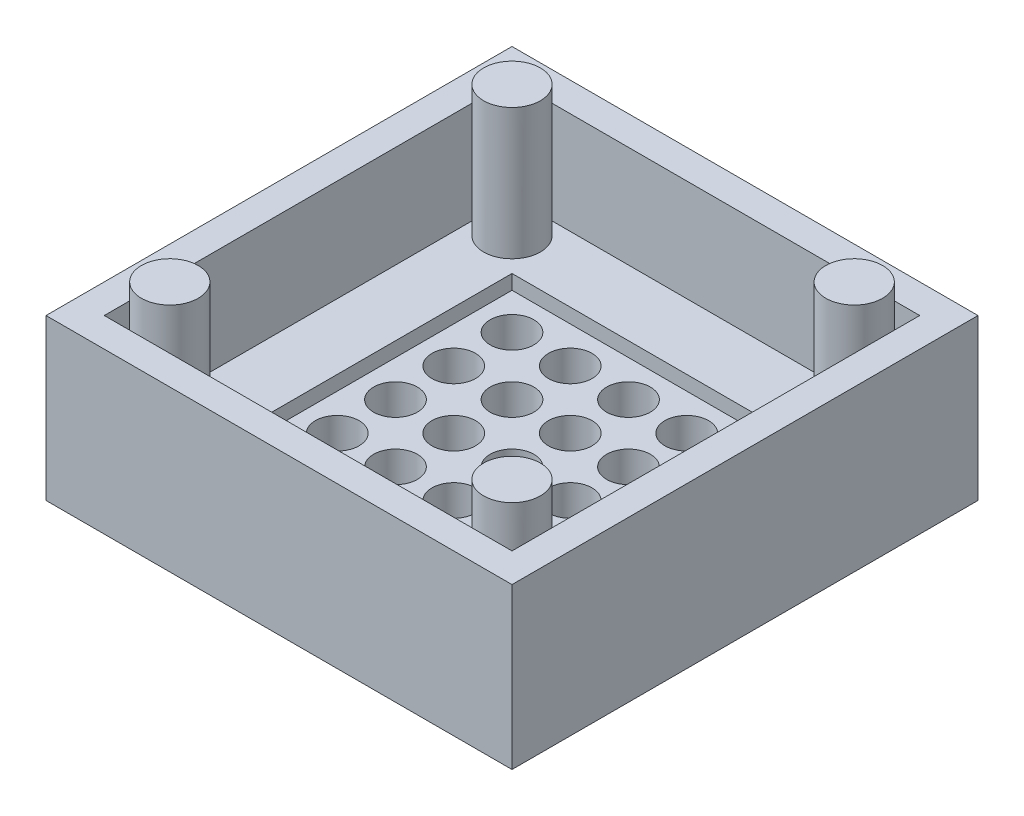
from build123d import *

# Parameters (mm, degrees)
SKETCH1_W           = 32
SKETCH1_H           = 32
BOSS_EXTRUDE1_DEPTH = 11
SKETCH2_W           = 28
SKETCH2_H           = 28
CUT_EXTRUDE1_DEPTH  = 7
SKETCH3_W           = 19
SKETCH3_H           = 19
CUT_EXTRUDE2_DEPTH  = 1.5
SKETCH4_W           = 17
SKETCH4_H           = 17
BOSS_EXTRUDE2_DEPTH = 1.5
SKETCH6_R           = 1.95
BOSS_EXTRUDE3_DEPTH = 9
SKETCH7_R           = 1.5
CUT_EXTRUDE3_DEPTH  = 3


with BuildPart() as part:
    # Sketch1 → Boss-Extrude1 (new body)
    with BuildSketch(Plane(origin=(0, 0, 0), x_dir=(1, 0, 0), z_dir=(0, 1, 0))):
        Rectangle(SKETCH1_W, SKETCH1_H)
    extrude(amount=BOSS_EXTRUDE1_DEPTH)

    # Sketch2 → Cut-Extrude1 (cut)
    with BuildSketch(Plane(origin=(0, 11, 0), x_dir=(1, 0, 0), z_dir=(0, 1, 0))):
        Rectangle(SKETCH2_W, SKETCH2_H)
    extrude(amount=-CUT_EXTRUDE1_DEPTH, mode=Mode.SUBTRACT)

    # Sketch3 → Cut-Extrude2 (cut)
    with BuildSketch(Plane(origin=(0, 4, 0), x_dir=(1, 0, 0), z_dir=(0, 1, 0))):
        Rectangle(SKETCH3_W, SKETCH3_H)
    extrude(amount=-CUT_EXTRUDE2_DEPTH, mode=Mode.SUBTRACT)

    # Sketch4 → Boss-Extrude2 (add)
    with BuildSketch(Plane(origin=(0, 2.5, 0), x_dir=(1, 0, 0), z_dir=(0, 1, 0))):
        Rectangle(SKETCH4_W, SKETCH4_H)
    extrude(amount=BOSS_EXTRUDE2_DEPTH)

    # Sketch6 → Boss-Extrude3 (add)
    with BuildSketch(Plane(origin=(0, 4, 0), x_dir=(1, 0, 0), z_dir=(0, 1, 0))):
        with Locations((-11.75, 11.75)):
            Circle(SKETCH6_R)
        with Locations((11.75, 11.75)):
            Circle(SKETCH6_R)
        with Locations((11.75, -11.75)):
            Circle(SKETCH6_R)
        with Locations((-11.75, -11.75)):
            Circle(SKETCH6_R)
    extrude(amount=BOSS_EXTRUDE3_DEPTH)

    # Sketch7 → Cut-Extrude3 (cut)
    with BuildSketch(Plane(origin=(0, 4, 0), x_dir=(1, 0, 0), z_dir=(0, 1, 0))):
        with Locations((-6, -6)):
            Circle(SKETCH7_R)
        with Locations((-2, -6)):
            Circle(SKETCH7_R)
        with Locations((2, -6)):
            Circle(SKETCH7_R)
        with Locations((6, -6)):
            Circle(SKETCH7_R)
        with Locations((-2, -2)):
            Circle(SKETCH7_R)
        with Locations((2, -2)):
            Circle(SKETCH7_R)
        with Locations((6, -2)):
            Circle(SKETCH7_R)
        with Locations((-2, 2)):
            Circle(SKETCH7_R)
        with Locations((2, 2)):
            Circle(SKETCH7_R)
        with Locations((6, 2)):
            Circle(SKETCH7_R)
        with Locations((-2, 6)):
            Circle(SKETCH7_R)
        with Locations((2, 6)):
            Circle(SKETCH7_R)
        with Locations((6, 6)):
            Circle(SKETCH7_R)
        with Locations((-6, -2)):
            Circle(SKETCH7_R)
        with Locations((-6, 2)):
            Circle(SKETCH7_R)
        with Locations((-6, 6)):
            Circle(SKETCH7_R)
    extrude(amount=-CUT_EXTRUDE3_DEPTH, mode=Mode.SUBTRACT)


solid = part.part
